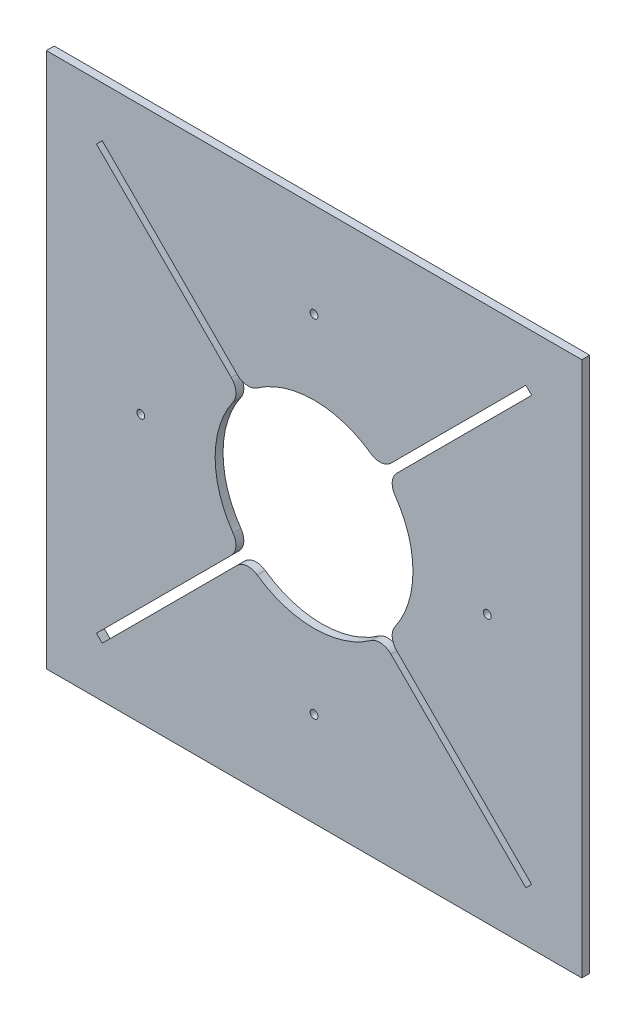
from build123d import *

# Parameters (mm, degrees)
SKETCH1_W           = 431.8
SKETCH1_H           = 431.8
BOSS_EXTRUDE1_DEPTH = 6.35
SKETCH2_R           = 79.756
CUT_EXTRUDE1_DEPTH  = 6.35
CUT_EXTRUDE2_DEPTH  = 6.35
FILLET1_R           = 12.7
SKETCH4_R           = 3.175
CUT_EXTRUDE3_DEPTH  = 6.35


with BuildPart() as part:
    # Sketch1 → Boss-Extrude1 (new body)
    with BuildSketch(Plane.XY):
        Rectangle(SKETCH1_W, SKETCH1_H)
    extrude(amount=BOSS_EXTRUDE1_DEPTH)

    # Sketch2 → Cut-Extrude1 (cut)
    with BuildSketch(Plane.XY.offset(6.35)):
        Circle(SKETCH2_R)
    extrude(amount=-CUT_EXTRUDE1_DEPTH, mode=Mode.SUBTRACT)

    # Sketch3 → Cut-Extrude2 (cut)
    with BuildSketch(Plane.XY.offset(6.35)):
        Polygon((-170.804471423, 175.474204606), (-175.474204606, 170.804471423), (-55.532184739, 50.862451556), (-50.862451556, 55.532184739), align=None)
        Polygon((175.474204606, 170.804471423), (170.804471423, 175.474204606), (50.862451556, 55.532184739), (55.532184739, 50.862451556), align=None)
        Polygon((170.804471423, -175.474204606), (175.474204606, -170.804471423), (55.532184739, -50.862451556), (50.862451556, -55.532184739), align=None)
        Polygon((-175.474204606, -170.804471423), (-170.804471423, -175.474204606), (-50.862451556, -55.532184739), (-55.532184739, -50.862451556), align=None)
    extrude(amount=-CUT_EXTRUDE2_DEPTH, mode=Mode.SUBTRACT)

    # Fillet1
    fillet1_edges = [part.edges().sort_by_distance(p)[0] for p in [
        (-54.012787894, 58.682521077, 3.175),
        (-58.682521077, 54.012787894, 3.175),
        (58.682521077, 54.012787894, 3.175),
        (54.012787894, 58.682521077, 3.175),
        (54.012787894, -58.682521077, 3.175),
        (58.682521077, -54.012787894, 3.175),
        (-58.682521077, -54.012787894, 3.175),
        (-54.012787894, -58.682521077, 3.175),
    ]]
    fillet(fillet1_edges, radius=FILLET1_R)

    # Sketch4 → Cut-Extrude3 (cut)
    with BuildSketch(Plane.XY.offset(6.35)):
        with Locations((0, 139.7)):
            Circle(SKETCH4_R)
        with Locations((139.7, 0)):
            Circle(SKETCH4_R)
        with Locations((0, -139.7)):
            Circle(SKETCH4_R)
        with Locations((-139.7, 0)):
            Circle(SKETCH4_R)
    extrude(amount=-CUT_EXTRUDE3_DEPTH, mode=Mode.SUBTRACT)


solid = part.part
